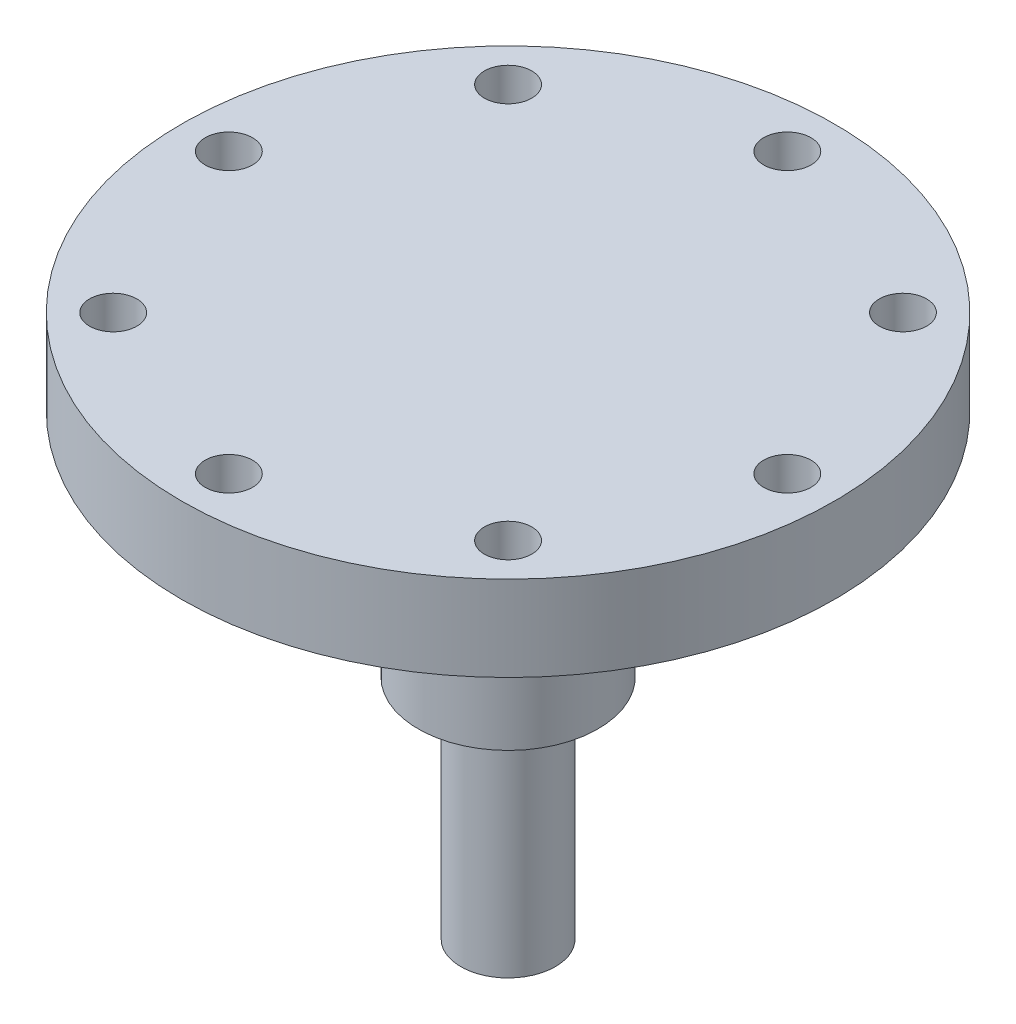
from build123d import *

# Parameters (mm, degrees)
CROQUIS1_R              = 17.25
CROQUIS1_R_2            = 1.25
SALIENTE_EXTRUIR1_DEPTH = 4.5
CROQUIS3_R              = 4.75
SALIENTE_EXTRUIR3_DEPTH = 12.175
CROQUIS4_R              = 6
SALIENTE_EXTRUIR4_DEPTH = 3
CROQUIS5_R              = 2.5
SALIENTE_EXTRUIR5_DEPTH = 12


with BuildPart() as part:
    # Croquis1 → Saliente-Extruir1 (new body)
    with BuildSketch(Plane(origin=(0, 0, 0), x_dir=(1, 0, 0), z_dir=(0, 1, 0))):
        Circle(CROQUIS1_R)
        with Locations((14.75, 0)):
            Circle(CROQUIS1_R_2, mode=Mode.SUBTRACT)
        with Locations((10.429825023, -10.429825023)):
            Circle(CROQUIS1_R_2, mode=Mode.SUBTRACT)
        with Locations((0, -14.75)):
            Circle(CROQUIS1_R_2, mode=Mode.SUBTRACT)
        with Locations((-10.429825023, -10.429825023)):
            Circle(CROQUIS1_R_2, mode=Mode.SUBTRACT)
        with Locations((-14.75, 0)):
            Circle(CROQUIS1_R_2, mode=Mode.SUBTRACT)
        with Locations((-10.429825023, 10.429825023)):
            Circle(CROQUIS1_R_2, mode=Mode.SUBTRACT)
        with Locations((0, 14.75)):
            Circle(CROQUIS1_R_2, mode=Mode.SUBTRACT)
        with Locations((10.429825023, 10.429825023)):
            Circle(CROQUIS1_R_2, mode=Mode.SUBTRACT)
    extrude(amount=SALIENTE_EXTRUIR1_DEPTH)

    # Croquis3 → Saliente-Extruir3 (add)
    with BuildSketch(Plane.XZ):
        Circle(CROQUIS3_R)
    extrude(amount=SALIENTE_EXTRUIR3_DEPTH)

    # Croquis4 → Saliente-Extruir4 (add)
    with BuildSketch(Plane.XZ):
        Circle(CROQUIS4_R)
    extrude(amount=SALIENTE_EXTRUIR4_DEPTH)

    # Croquis5 → Saliente-Extruir5 (add)
    with BuildSketch(Plane.XZ.offset(12.175)):
        Circle(CROQUIS5_R)
    extrude(amount=SALIENTE_EXTRUIR5_DEPTH)


solid = part.part
